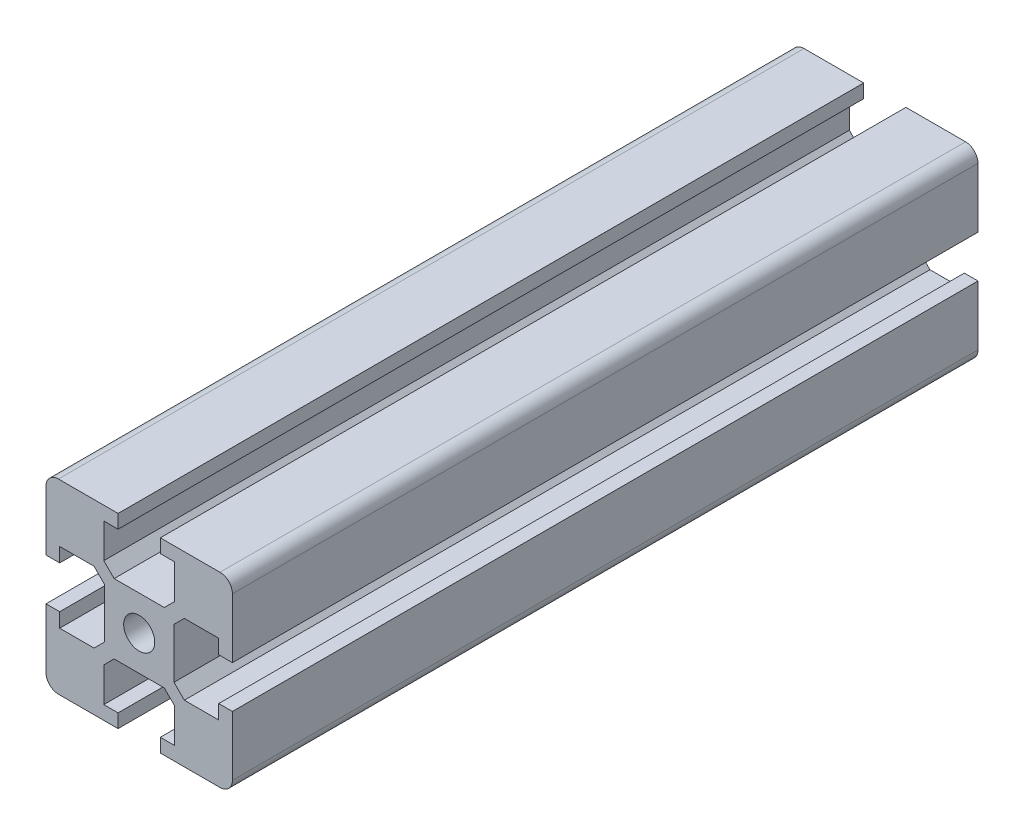
from build123d import *

# Parameters (mm, degrees)
SKETCH1_R           = 1.25
BOSS_EXTRUDE1_DEPTH = 60
FILLET1_R           = 1


with BuildPart() as part:
    # Sketch1 → Boss-Extrude1 (new body)
    with BuildSketch(Plane.XY):
        Polygon((7.5, -7.5), (1.7, -7.5), (1.7, -6.4), (2.85, -6.4), (2.85, -3.63183498), (2.01816502, -2.8), (-2.01816502, -2.8), (-2.85, -3.63183498), (-2.85, -6.4), (-1.7, -6.4), (-1.7, -7.5), (-7.5, -7.5), (-7.5, -1.7), (-6.4, -1.7), (-6.4, -2.85), (-3.63183498, -2.85), (-2.8, -2.01816502), (-2.8, 2.01816502), (-3.63183498, 2.85), (-6.4, 2.85), (-6.4, 1.7), (-7.5, 1.7), (-7.5, 7.5), (-1.7, 7.5), (-1.7, 6.4), (-2.85, 6.4), (-2.85, 3.63183498), (-2.01816502, 2.8), (2.01816502, 2.8), (2.85, 3.63183498), (2.85, 6.4), (1.7, 6.4), (1.7, 7.5), (7.5, 7.5), (7.5, 1.7), (6.4, 1.7), (6.4, 2.85), (3.63183498, 2.85), (2.8, 2.01816502), (2.8, -2.01816502), (3.63183498, -2.85), (6.4, -2.85), (6.4, -1.7), (7.5, -1.7), align=None)
        Circle(SKETCH1_R, mode=Mode.SUBTRACT)
    extrude(amount=BOSS_EXTRUDE1_DEPTH)

    # Fillet1
    fillet1_edges = [part.edges().sort_by_distance(p)[0] for p in [
        (-7.5, 7.5, 30),
        (7.5, 7.5, 30),
        (7.5, -7.5, 30),
        (-7.5, -7.5, 30),
    ]]
    fillet(fillet1_edges, radius=FILLET1_R)


solid = part.part
